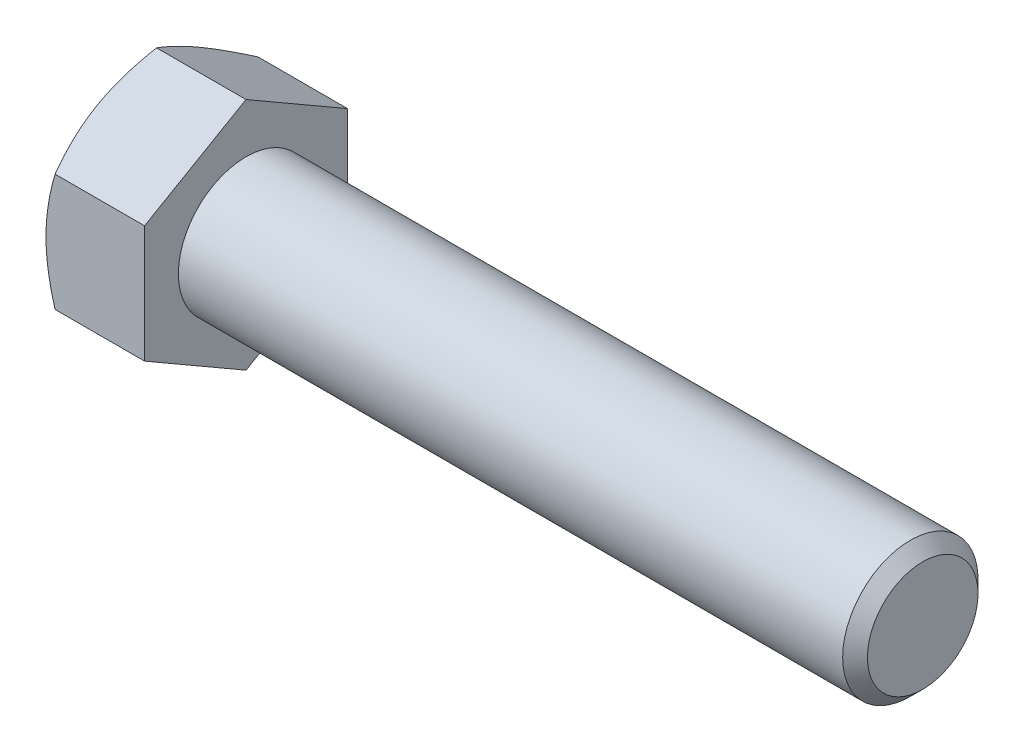
from build123d import *

# Parameters (mm, degrees)
BASEHEAD_DEPTH = 9.2456


with BuildPart() as part:
    # Sketch1 → BaseHead (new body)
    with BuildSketch(Plane(origin=(0, 0, 0), x_dir=(0, 0, -1), z_dir=(1, 0, 0))):
        Polygon((9.525, 5.499261314), (9.525, -5.499261314), (0, -10.998522628), (-9.525, -5.499261314), (-9.525, 5.499261314), (0, 10.998522628), align=None)
    extrude(amount=BASEHEAD_DEPTH)

    # BodySke → BaseBody (revolve)
    with BuildSketch(Plane.XY):
        Polygon((0, 0), (72.7456, 0), (72.7456, 5.18668), (71.58228, 6.35), (0, 6.35), align=None)
    revolve(axis=Axis((0, 0, 0), (1, 0, 0)))

    # Sketch3 → HeadChamfer (revolve, cut)
    with BuildSketch(Plane.XY):
        Polygon((0, 9.525), (4.516912895, 17.348522628), (4.516912895, 23.698522628), (-12.7, 23.698522628), (-12.7, 9.525), align=None)
    revolve(axis=Axis((0, 0, 0), (1, 0, 0)), mode=Mode.SUBTRACT)


solid = part.part
